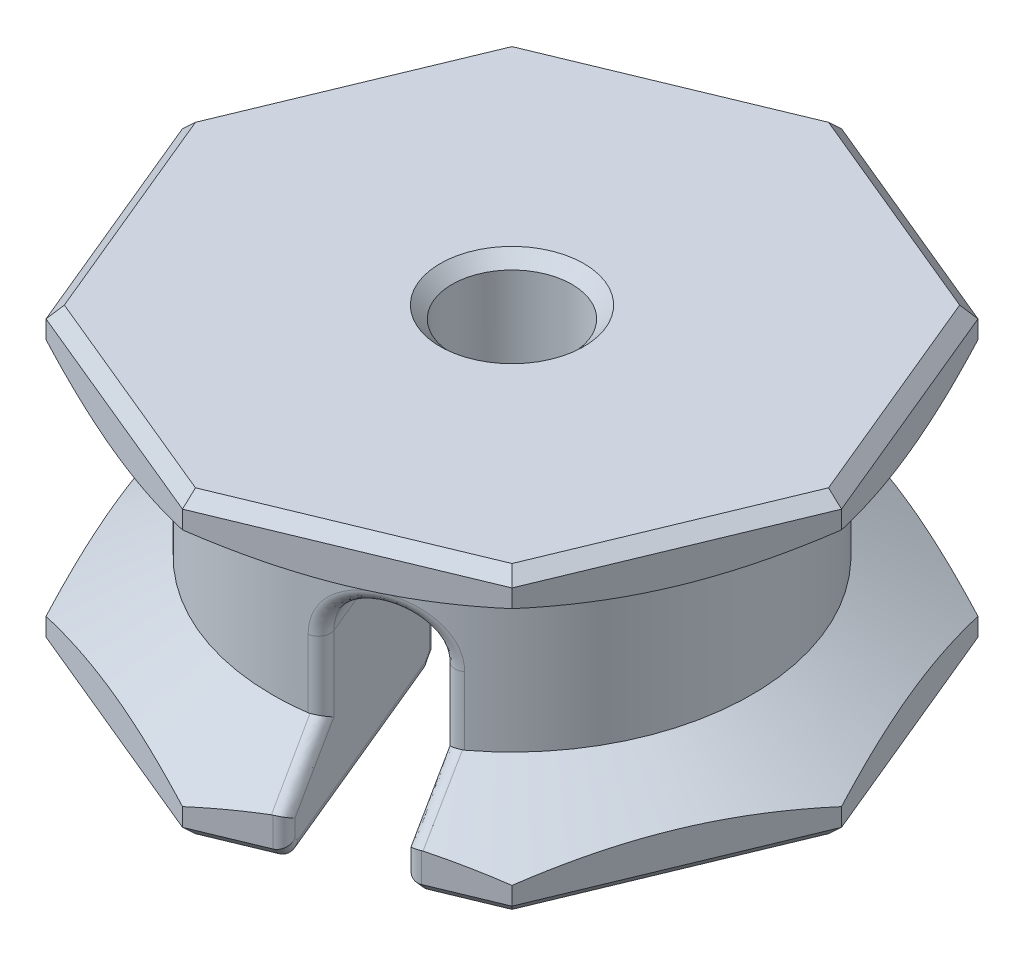
from build123d import *

# Parameters (mm, degrees)
SKETCH3_OUTSIDE_W  = 30.536
SKETCH3_OUTSIDE_H  = 30.536
CUT_EXTRUDE1_DEPTH = 10
SKETCH4_R          = 2
CUT_EXTRUDE2_DEPTH = 11
CUT_EXTRUDE3_START = -8.839802
CUT_EXTRUDE3_DEPTH = 8.839802
CHAMFER2_SIZE      = 0.4
FILLET2_R          = 0.4


with BuildPart() as part:
    # Sketch2 → Revolve1 (revolve)
    with BuildSketch(Plane.XY):
        Polygon((0, 5), (11, 5), (11, 4), (8, 2.267949192), (8, -2.267949192), (11, -4), (11, -5), (0, -5), align=None)
    revolve(axis=Axis((0, 5, 0), (0, -1, 0)))

    # Sketch3 outside → Cut-Extrude1 (cut)
    with BuildSketch(Plane(origin=(0, 5, 0), x_dir=(1, 0, 0), z_dir=(0, 1, 0))):
        Rectangle(SKETCH3_OUTSIDE_W, SKETCH3_OUTSIDE_H)
        Polygon((0, 11), (-7.778174593, 7.778174593), (-11, 0), (-7.778174593, -7.778174593), (0, -11), (7.778174593, -7.778174593), (11, 0), (7.778174593, 7.778174593), align=None, mode=Mode.SUBTRACT)
    extrude(amount=-CUT_EXTRUDE1_DEPTH, mode=Mode.SUBTRACT)

    # Sketch4 → Cut-Extrude2 (cut, through all)
    with BuildSketch(Plane.XZ.offset(5)):
        Circle(SKETCH4_R)
    extrude(amount=-CUT_EXTRUDE2_DEPTH, mode=Mode.SUBTRACT)

    # Sketch6 → Cut-Extrude3 (cut)
    with BuildSketch(Plane(origin=(3.889087297, 0, 9.389087297), x_dir=(0.923879533, 0, -0.382683432), z_dir=(0.382683432, 0, 0.923879533)).offset(CUT_EXTRUDE3_START)):
        with BuildLine():
            Line((-1.5, 0), (-1.5, -5))
            Line((-1.5, -5), (1.5, -5))
            Line((1.5, -5), (1.5, 0))
            ThreePointArc((1.5, 0), (0, 1.5), (-1.5, 0))
        make_face()
    extrude(amount=CUT_EXTRUDE3_DEPTH, mode=Mode.SUBTRACT)

    # Chamfer2
    chamfer2_edges = [part.edges().sort_by_distance(p)[0] for p in [
        (-2, 5, 0),
        (-1.058500495, -5, -1.696931555),
        (6.526540594, -5, 8.296618371),
        (1.251633999, -5, 10.481556223),
        (9.389087297, -5, 3.889087297),
        (9.389087297, -5, -3.889087297),
        (3.889087297, -5, -9.389087297),
        (-3.889087297, -5, -9.389087297),
        (-9.389087297, -5, -3.889087297),
        (-9.389087297, -5, 3.889087297),
        (-3.889087297, -5, 9.389087297),
        (3.889087297, 5, -9.389087297),
        (9.389087297, 5, -3.889087297),
        (9.389087297, 5, 3.889087297),
        (3.889087297, 5, 9.389087297),
        (-3.889087297, 5, 9.389087297),
        (-9.389087297, 5, 3.889087297),
        (-9.389087297, 5, -3.889087297),
        (-3.889087297, 5, -9.389087297),
    ]]
    chamfer(chamfer2_edges, length=CHAMFER2_SIZE)

    # Fillet2
    fillet2_edges = [part.edges().sort_by_distance(p)[0] for p in [
        (1.892061895, -2.3, 0.648152594),
        (0.765366865, 1.5, 1.847759065),
        (-0.879576702, -2.3, 1.796202891),
        (2.426731311, -4.8, 9.778336539),
        (2.503267998, -4.090068985, 9.963112445),
        (2.062498981, -2.923175764, 8.899001906),
        (1.621351819, -1.133974596, 7.833978445),
        (3.061467461, 1.500000006, 7.391036258),
        (4.392990416, -1.133974596, 6.685928148),
        (4.834137578, -2.923175764, 7.750951609),
        (5.274906595, -4.090068985, 8.815062148),
        (5.198369909, -4.8, 8.630286241),
        (3.612304851, -5, 4.801186468),
        (1.998897786, -4.794668162, 0.90607725),
        (0.840666253, -5, 5.949236765),
        (-0.772740812, -4.794668162, 2.054127547),
    ]]
    fillet(fillet2_edges, radius=FILLET2_R)


solid = part.part
